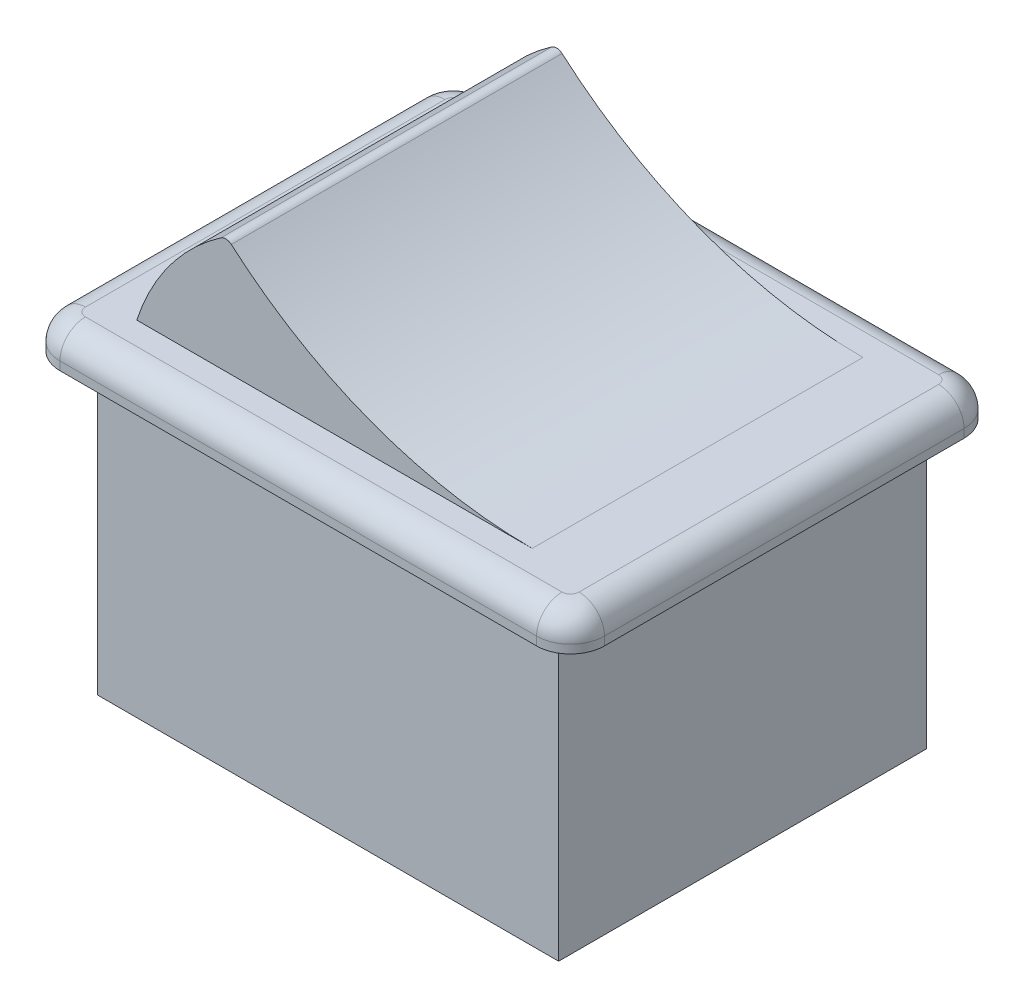
from build123d import *

# Parameters (mm, degrees)
BOSS_EXTRUDE1_DEPTH = 2
FILLET1_R           = 1.5
BOSS_EXTRUDE2_DEPTH = 9.75
SKETCH4_W           = 27.2
SKETCH4_H           = 17.2
BOSS_EXTRUDE3_DEPTH = 10.85


with BuildPart() as part:
    # Sketch1 → Boss-Extrude1 (new body)
    with BuildSketch(Plane(origin=(0, 0, 0), x_dir=(1, 0, 0), z_dir=(0, 1, 0))):
        with BuildLine():
            Line((-14.05, 12.6), (14.05, 12.6))
            ThreePointArc((14.05, 12.6), (15.464213562, 12.014213562), (16.05, 10.6))
            Line((16.05, 10.6), (16.05, -10.6))
            ThreePointArc((16.05, -10.6), (15.464213562, -12.014213562), (14.05, -12.6))
            Line((14.05, -12.6), (-14.05, -12.6))
            ThreePointArc((-14.05, -12.6), (-15.464213562, -12.014213562), (-16.05, -10.6))
            Line((-16.05, -10.6), (-16.05, 10.6))
            ThreePointArc((-16.05, 10.6), (-15.464213562, 12.014213562), (-14.05, 12.6))
        make_face()
    extrude(amount=BOSS_EXTRUDE1_DEPTH)

    # Fillet1
    fillet1_edges = [part.edges().sort_by_distance(p)[0] for p in [
        (-15.464213562, 2, -12.014213562),
        (-16.05, 2, 0),
        (-15.464213562, 2, 12.014213562),
        (0, 2, 12.6),
        (15.464213562, 2, 12.014213562),
        (16.05, 2, 0),
        (15.464213562, 2, -12.014213562),
        (0, 2, -12.6),
    ]]
    fillet(fillet1_edges, radius=FILLET1_R)

    # Sketch3 → Boss-Extrude2 (add, symmetric)
    with BuildSketch(Plane.XY):
        with BuildLine():
            Line((-12.369316877, 2), (10.942988923, 2))
            ThreePointArc((10.942988923, 2), (1.470491732, 3.716175191), (-6.79782289, 8.646533558))
            ThreePointArc((-6.79782289, 8.646533558), (-7.098799524, 8.768857552), (-7.4114107, 8.680402213))
            ThreePointArc((-7.4114107, 8.680402213), (-10.439168516, 5.747500287), (-12.369316877, 2))
        make_face()
    extrude(amount=BOSS_EXTRUDE2_DEPTH, both=True)

    # Sketch4 → Boss-Extrude3 (add, symmetric)
    with BuildSketch(Plane.XY):
        with Locations((0, -8.6)):
            Rectangle(SKETCH4_W, SKETCH4_H)
    extrude(amount=BOSS_EXTRUDE3_DEPTH, both=True)


solid = part.part
